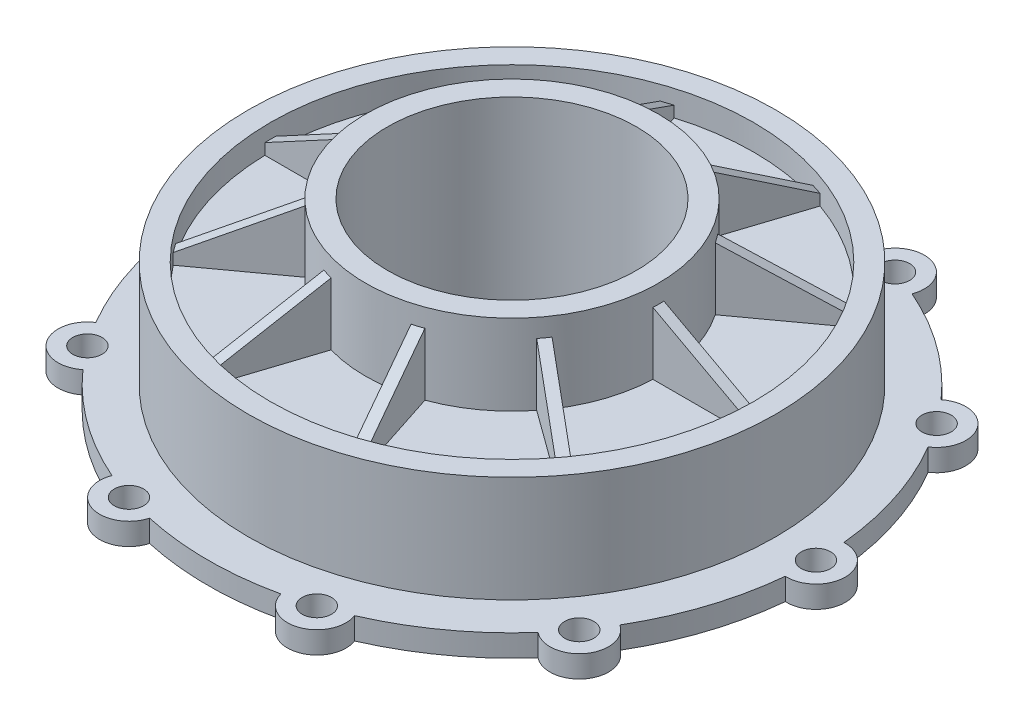
from build123d import *

# Parameters (mm, degrees)
SKETCH3_R           = 8
BOSS_EXTRUDE1_DEPTH = 6
SKETCH4_R           = 4
CUT_EXTRUDE1_DEPTH  = 7
CIRPATTERN2_COUNT   = 10
RIB1_REACH          = 88.938
SKETCH2_WALL_W      = 205.405027826
SKETCH2_WALL_H      = 3
CIRPATTERN1_COUNT   = 10
RIB2_REACH          = 52
SKETCH5_WALLS_W     = 128
SKETCH5_WALLS_H     = 3
CIRPATTERN3_COUNT   = 10


with BuildPart() as part:
    # Sketch1 → Revolve1 (revolve)
    with BuildSketch(Plane.XY, mode=Mode.PRIVATE) as revolve1_sk:
        Polygon((34, 0), (34, 50), (40, 50), (40, 28), (66, 28), (66, 35), (72, 35), (72, 6), (83, 6), (83, 0), (66, 0), (66, 22), (40, 22), (40, 0), align=None)
    revolve(revolve1_sk.sketch.rotate(Axis((0, 0, 0), (0, 1, 0)), 90), axis=Axis((0, 0, 0), (0, 1, 0)))  # turned: the seam where the file's is

    # Sketch3 → Boss-Extrude1 (add)
    with BuildSketch(Plane(origin=(0, 6, 0), x_dir=(1, 0, 0), z_dir=(0, 1, 0))):
        with Locations((-83, 0)):
            Circle(SKETCH3_R)
    boss_extrude1 = extrude(amount=-BOSS_EXTRUDE1_DEPTH)

    # Sketch4 → Cut-Extrude1 (cut, through all)
    with BuildSketch(Plane(origin=(0, 6, 0), x_dir=(1, 0, 0), z_dir=(0, 1, 0))):
        with Locations(Location((-83, 0, 0), (0, 0, 270))):  # turned: the seam where the file's is
            Circle(SKETCH4_R)
    cut_extrude1 = extrude(amount=-CUT_EXTRUDE1_DEPTH, mode=Mode.SUBTRACT)

    # CirPattern2: Boss-Extrude1, Cut-Extrude1 ×10 about axis
    cirpattern2_axis = Axis((0, 0, 0), (0, 1, 0))
    add([boss_extrude1.rotate(cirpattern2_axis, i * 360 / CIRPATTERN2_COUNT) for i in range(1, CIRPATTERN2_COUNT)])
    add([cut_extrude1.rotate(cirpattern2_axis, i * 360 / CIRPATTERN2_COUNT) for i in range(1, CIRPATTERN2_COUNT)], mode=Mode.SUBTRACT)

    # Sketch2 wall → Rib1 (add, up to next)
    with BuildSketch(Plane(origin=(-53, 38, 0), x_dir=(-0.8804711, -0.474099823, 0), z_dir=(0.474099823, -0.8804711, 0)), mode=Mode.PRIVATE) as rib1_sk1:
        Rectangle(SKETCH2_WALL_W, SKETCH2_WALL_H)
    rib1_tool1 = extrude(rib1_sk1.sketch, amount=RIB1_REACH, mode=Mode.PRIVATE) - part.part
    rib1 = rib1_tool1.solids().sort_by_distance((-53, 38, 0))[0]
    add(rib1)

    # CirPattern1: Rib1 ×10 about axis
    cirpattern1_axis = Axis((0, 0, 0), (0, 1, 0))
    for i in range(1, CIRPATTERN1_COUNT):
        add(rib1.rotate(cirpattern1_axis, i * 360 / CIRPATTERN1_COUNT))

    # Sketch5 walls → Rib2 (add, up to next)
    with BuildSketch(Plane.XZ, mode=Mode.PRIVATE) as rib2_sk1:
        with Locations((-53, 0)):
            Rectangle(SKETCH5_WALLS_W, SKETCH5_WALLS_H)
    rib2_tool1 = extrude(rib2_sk1.sketch, amount=-RIB2_REACH, mode=Mode.PRIVATE) - part.part
    rib2 = rib2_tool1.solids().sort_by_distance((-53, 0, 0))[0]
    add(rib2)

    # CirPattern3: Rib2 ×10 about axis
    cirpattern3_axis = Axis((0, 0, 0), (0, -1, 0))
    for i in range(1, CIRPATTERN3_COUNT):
        add(rib2.rotate(cirpattern3_axis, i * 360 / CIRPATTERN3_COUNT))


solid = part.part
